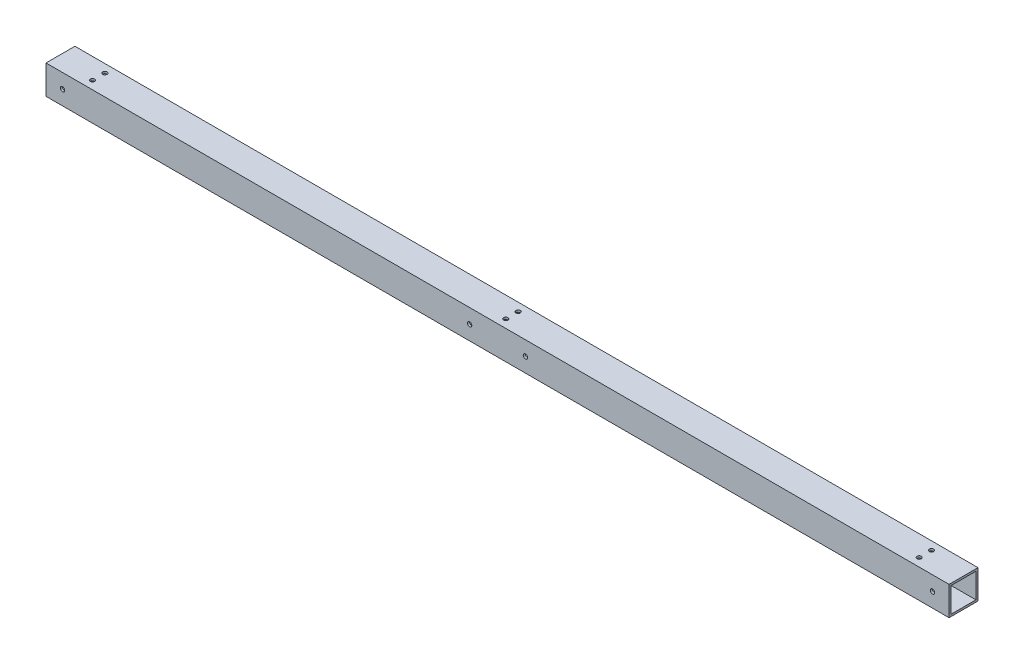
from build123d import *

# Parameters (mm, degrees)
BOSS_EXTRUDE1_DEPTH              = 693.7375
BOSS_EXTRUDE1_DEPTH_BACK         = 693.7375
SKETCH1_W                        = 44.45
SKETCH1_H                        = 44.45
SKETCH1_W_2                      = 38.1
SKETCH1_H_2                      = 38.1
F_17_64_0_26563_DIAMETER_HOLE2_D = 6.747002
F_17_64_0_26563_DIAMETER_HOLE1_D = 6.747002


with BuildPart() as part:
    # Sketch1 → Boss-Extrude1 (new, two sides: drawn at the far end of the back side and taken through both)
    with BuildSketch(Plane(origin=(0, 0, 0), x_dir=(0, 0, -1), z_dir=(1, 0, 0)).offset(-BOSS_EXTRUDE1_DEPTH_BACK)):
        Rectangle(SKETCH1_W, SKETCH1_H)
        Rectangle(SKETCH1_W_2, SKETCH1_H_2, mode=Mode.SUBTRACT)
    extrude(amount=BOSS_EXTRUDE1_DEPTH + BOSS_EXTRUDE1_DEPTH_BACK)

    # 17_64 _0.26563_ Diameter Hole2 (through all)
    with Locations(Plane.XY.offset(22.225)):
        with Locations((42.8625, 0), (-668.3375, 0), (668.3375, 0), (-42.8625, 0)):
            Hole(F_17_64_0_26563_DIAMETER_HOLE2_D / 2)

    # 17_64 _0.26563_ Diameter Hole1 (through all)
    with Locations(Plane(origin=(0, -22.225, 0), x_dir=(-1, 0, 0), z_dir=(0, -1, 0))):
        with Locations((0, 9.525), (0, -9.525), (-635, 9.525), (-635, -9.525), (635, -9.525), (635, 9.525)):
            Hole(F_17_64_0_26563_DIAMETER_HOLE1_D / 2)


solid = part.part
